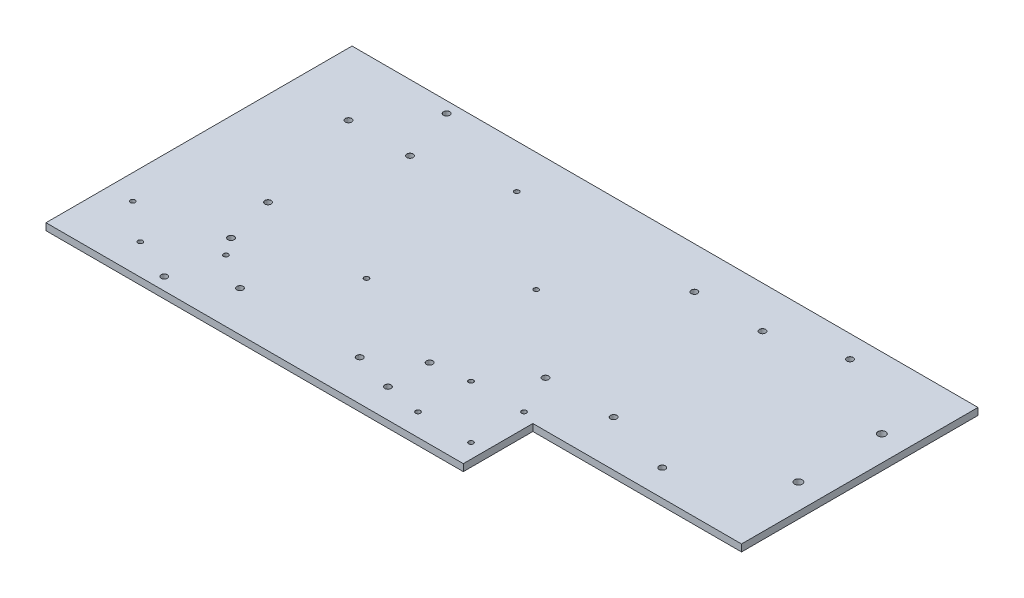
from build123d import *

# Parameters (mm, degrees)
BOSS_EXTRUDE1_DEPTH            = 5
M3_CLEARANCE_HOLE1_D           = 3.4
M3_CLEARANCE_HOLE1_CSINK_D     = 3.45
M3_CLEARANCE_HOLE1_CSINK_ANGLE = 90
M4_CLEARANCE_HOLE1_D           = 4.5
M4_CLEARANCE_HOLE1_CSINK_D     = 4.55
M4_CLEARANCE_HOLE1_CSINK_ANGLE = 90
M5_CLEARANCE_HOLE1_D           = 5.5
M5_CLEARANCE_HOLE1_CSINK_D     = 5.55
M5_CLEARANCE_HOLE1_CSINK_ANGLE = 90
M4_CLEARANCE_HOLE2_D           = 4.5
M4_CLEARANCE_HOLE2_CSINK_D     = 4.55
M4_CLEARANCE_HOLE2_CSINK_ANGLE = 90


with BuildPart() as part:
    # Sketch1 → Boss-Extrude1 (new body)
    with BuildSketch(Plane(origin=(0, 0, 0), x_dir=(1, 0, 0), z_dir=(0, 1, 0))):
        Polygon((0, 0), (0, -220), (300, -220), (300, -170), (450, -170), (450, 0), align=None)
    extrude(amount=BOSS_EXTRUDE1_DEPTH)

    # M3 Clearance Hole1 (through all)
    with Locations(Plane(origin=(0, 5, 0), x_dir=(1, 0, 0), z_dir=(0, 1, 0))):
        with Locations((17.79, -175.47), (45.79, -197.97), (84.79, -175.47), (251.48, -204.04), (251.48, -165.94), (149.84, -139.45), (217.84, -85.45), (149.84, -31.45), (289.58, -165.94), (289.58, -204.04)):
            CounterSinkHole(M3_CLEARANCE_HOLE1_D / 2, M3_CLEARANCE_HOLE1_CSINK_D / 2, counter_sink_angle=M3_CLEARANCE_HOLE1_CSINK_ANGLE)

    # M4 Clearance Hole1 (through all)
    with Locations(Plane(origin=(0, 5, 0), x_dir=(1, 0, 0), z_dir=(0, 1, 0))):
        with Locations((44.95, -47.48), (89.15, -47.48), (67.05, -127.48), (276.07, -29.99), (325.07, -29.99), (276.07, -136.99), (325.07, -136.99), (225, -199.19), (225, -169.19), (110.5, -191), (196.5, -191)):
            CounterSinkHole(M4_CLEARANCE_HOLE1_D / 2, M4_CLEARANCE_HOLE1_CSINK_D / 2, counter_sink_angle=M4_CLEARANCE_HOLE1_CSINK_ANGLE)

    # M5 Clearance Hole1 (through all)
    with Locations(Plane(origin=(431.86, 5, 50.98), x_dir=(0, 0, 1), z_dir=(0, 1, 0))):
        with Locations((0, 0), (60, 0)):
            CounterSinkHole(M5_CLEARANCE_HOLE1_D / 2, M5_CLEARANCE_HOLE1_CSINK_D / 2, counter_sink_angle=M5_CLEARANCE_HOLE1_CSINK_ANGLE)

    # M4 Clearance Hole2 (through all)
    with Locations(Plane(origin=(0, 5, 0), x_dir=(1, 0, 0), z_dir=(0, 1, 0))):
        with Locations((76, -8), (76, -163), (76, -211), (374, -151), (374, -16)):
            CounterSinkHole(M4_CLEARANCE_HOLE2_D / 2, M4_CLEARANCE_HOLE2_CSINK_D / 2, counter_sink_angle=M4_CLEARANCE_HOLE2_CSINK_ANGLE)


solid = part.part
